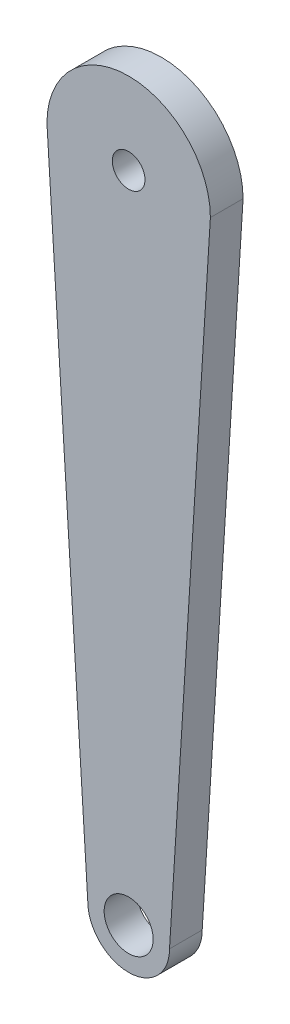
from build123d import *

# Parameters (mm, degrees)
SKETCH1_R           = 7.5
SKETCH1_R_2         = 13
BOSS_EXTRUDE1_DEPTH = 10
SKETCH2_R           = 13
SKETCH2_R_2         = 5
BOSS_EXTRUDE2_DEPTH = 10


with BuildPart() as part:
    # Sketch1 → Boss-Extrude1 (new body)
    with BuildSketch(Plane.XY):
        with BuildLine():
            ThreePointArc((25, 100), (0, 125), (-25, 100))
            Line((-25, 100), (-24.805447471, 96.887159533))
            Line((-24.805447471, 96.887159533), (-12.5, -100))
            ThreePointArc((-12.5, -100), (0, -112.5), (12.5, -100))
            Line((12.5, -100), (24.805447471, 96.887159533))
            Line((24.805447471, 96.887159533), (25, 100))
        make_face()
        with Locations((0, -100)):
            Circle(SKETCH1_R, mode=Mode.SUBTRACT)
        with Locations((0, 100)):
            Circle(SKETCH1_R_2, mode=Mode.SUBTRACT)
    extrude(amount=BOSS_EXTRUDE1_DEPTH)

    # Sketch2 → Boss-Extrude2 (add)
    with BuildSketch(Plane.XY.offset(10)):
        with Locations((0, 100)):
            Circle(SKETCH2_R)
        with Locations((0, 100)):
            Circle(SKETCH2_R_2, mode=Mode.SUBTRACT)
    extrude(amount=-BOSS_EXTRUDE2_DEPTH)


solid = part.part
